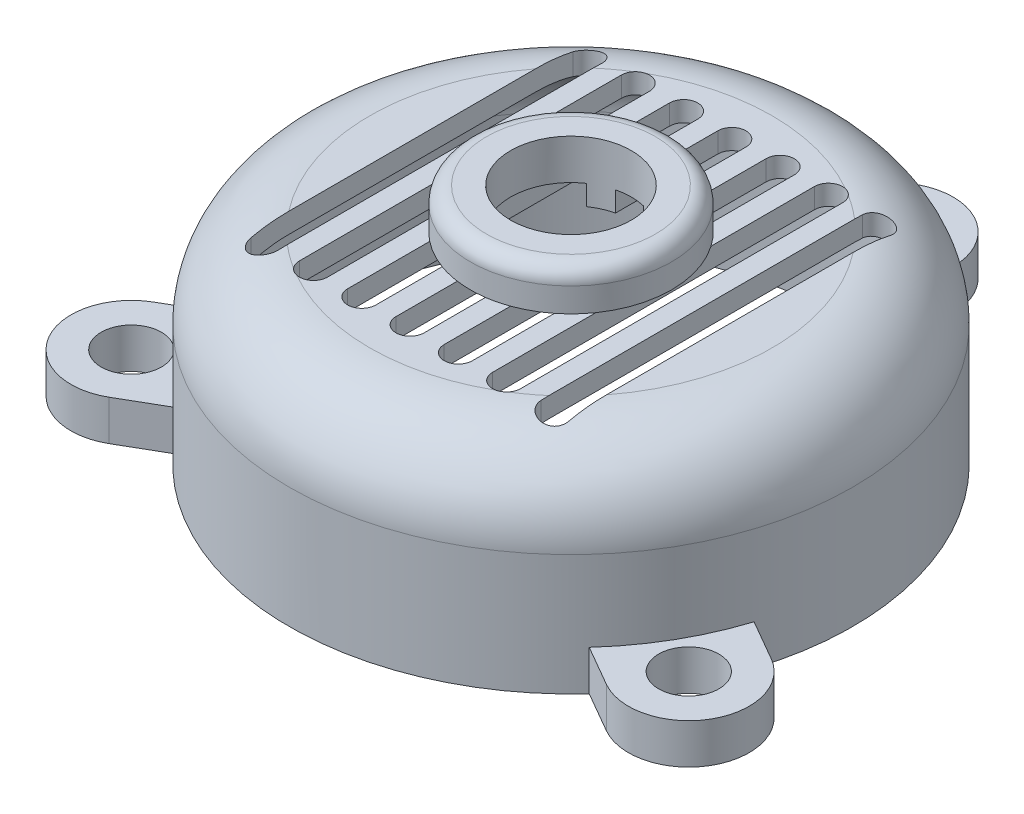
from build123d import *

# Parameters (mm, degrees)
SHELL1_T            = -0.25
BOSS_EXTRUDE2_START = 2.25
SKETCH2_R           = 1.25
BOSS_EXTRUDE2_DEPTH = 0.75
SKETCH4_R           = 0.75
CUT_EXTRUDE1_DEPTH  = 1
FILLET1_R           = 0.2
CUT_EXTRUDE2_START  = 2.5
CUT_EXTRUDE2_DEPTH  = 1
SKETCH6_R           = 0.375
BOSS_EXTRUDE3_DEPTH = 0.5
CIRPATTERN2_COUNT   = 3


with BuildPart() as part:
    # Sketch1 → Revolve1 (revolve)
    with BuildSketch(Plane.XY, mode=Mode.PRIVATE) as revolve1_sk:
        with BuildLine():
            Line((-3.5, 0), (-3.5, 1.5))
            ThreePointArc((-3.5, 1.5), (-3.207106781, 2.207106781), (-2.5, 2.5))
            Line((-2.5, 2.5), (0, 2.5))
            Line((0, 2.5), (0, 0))
            Line((0, 0), (-3.5, 0))
        make_face()
    revolve(revolve1_sk.sketch.rotate(Axis((0, 0, 0), (0, 1, 0)), 270), axis=Axis((0, 0, 0), (0, 1, 0)))

    # Shell1
    shell1_openings = [part.faces().sort_by_distance(p)[0] for p in [
        (0, 0, 0),
    ]]
    offset(amount=SHELL1_T, openings=shell1_openings, kind=Kind.INTERSECTION)

    # Sketch2 → Boss-Extrude2 (add)
    with BuildSketch(Plane(origin=(0, 0, 0), x_dir=(1, 0, 0), z_dir=(0, 1, 0)).offset(BOSS_EXTRUDE2_START)):
        with Locations(Location((0, 0, 0), (0, 0, 90))):
            Circle(SKETCH2_R)
    extrude(amount=BOSS_EXTRUDE2_DEPTH)

    # Sketch4 → Cut-Extrude1 (cut)
    with BuildSketch(Plane(origin=(0, 3, 0), x_dir=(1, 0, 0), z_dir=(0, 1, 0))):
        with Locations(Location((0, 0, 0), (0, 0, 270))):
            Circle(SKETCH4_R)
    extrude(amount=-CUT_EXTRUDE1_DEPTH, mode=Mode.SUBTRACT)

    # Fillet1
    fillet1_edges = [part.edges().sort_by_distance(p)[0] for p in [
        (0, 3, 1.25),
    ]]
    fillet(fillet1_edges, radius=FILLET1_R)

    # Sketch5 → Cut-Extrude2 (cut)
    with BuildSketch(Plane(origin=(0, 0, 0), x_dir=(1, 0, 0), z_dir=(0, 1, 0)).offset(CUT_EXTRUDE2_START)):
        with BuildLine():
            Line((1.975, 2), (1.975, -2))
            ThreePointArc((1.975, -2), (1.8, -2.175), (1.625, -2))
            Line((1.625, -2), (1.625, 2))
            ThreePointArc((1.625, 2), (1.8, 2.175), (1.975, 2))
        make_face()
        with BuildLine():
            Line((1.375, 2), (1.375, -2))
            ThreePointArc((1.375, -2), (1.2, -2.175), (1.025, -2))
            Line((1.025, -2), (1.025, 2))
            ThreePointArc((1.025, 2), (1.2, 2.175), (1.375, 2))
        make_face()
        with BuildLine():
            Line((0.775, 2), (0.775, -2))
            ThreePointArc((0.775, -2), (0.6, -2.175), (0.425, -2))
            Line((0.425, -2), (0.425, 2))
            ThreePointArc((0.425, 2), (0.6, 2.175), (0.775, 2))
        make_face()
        with BuildLine():
            Line((0.175, 2), (0.175, -2))
            ThreePointArc((0.175, -2), (0, -2.175), (-0.175, -2))
            Line((-0.175, -2), (-0.175, 2))
            ThreePointArc((-0.175, 2), (0, 2.175), (0.175, 2))
        make_face()
        with BuildLine():
            Line((-0.425, 2), (-0.425, -2))
            ThreePointArc((-0.425, -2), (-0.6, -2.175), (-0.775, -2))
            Line((-0.775, -2), (-0.775, 2))
            ThreePointArc((-0.775, 2), (-0.6, 2.175), (-0.425, 2))
        make_face()
        with BuildLine():
            Line((-1.025, 2), (-1.025, -2))
            ThreePointArc((-1.025, -2), (-1.2, -2.175), (-1.375, -2))
            Line((-1.375, -2), (-1.375, 2))
            ThreePointArc((-1.375, 2), (-1.2, 2.175), (-1.025, 2))
        make_face()
        with BuildLine():
            Line((-1.625, 2), (-1.625, -2))
            ThreePointArc((-1.625, -2), (-1.8, -2.175), (-1.975, -2))
            Line((-1.975, -2), (-1.975, 2))
            ThreePointArc((-1.975, 2), (-1.8, 2.175), (-1.625, 2))
        make_face()
    extrude(amount=-CUT_EXTRUDE2_DEPTH, mode=Mode.SUBTRACT)

    # Sketch6 → Boss-Extrude3 (add)
    with BuildSketch(Plane(origin=(0, 0, 0), x_dir=(1, 0, 0), z_dir=(0, 1, 0))):
        with BuildLine():
            Line((-0.75, 4), (-0.75, 3.418698583))
            ThreePointArc((-0.75, 3.418698583), (0, 3.5), (0.75, 3.418698583))
            Line((0.75, 3.418698583), (0.75, 4))
            ThreePointArc((0.75, 4), (0, 4.75), (-0.75, 4))
        make_face()
        with Locations(Location((0, 4, 0), (0, 0, 270))):
            Circle(SKETCH6_R, mode=Mode.SUBTRACT)
    boss_extrude3 = extrude(amount=BOSS_EXTRUDE3_DEPTH)

    # CirPattern2: Boss-Extrude3 ×3 about axis
    cirpattern2_axis = Axis((0, 0, 0), (0, 1, 0))
    for i in range(1, CIRPATTERN2_COUNT):
        add(boss_extrude3.rotate(cirpattern2_axis, i * 360 / CIRPATTERN2_COUNT))


solid = part.part
